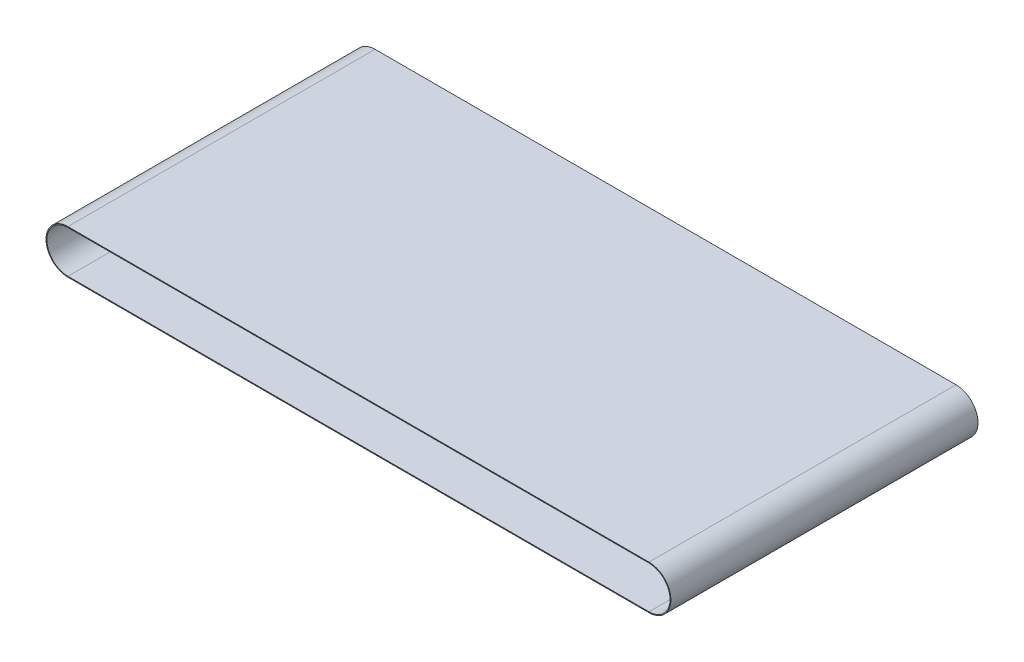
from build123d import *

# Parameters (mm, degrees)
SKETCH_2_W = 370
SKETCH_2_H = 1


with BuildPart() as part:
    # 扫描1: sweep along a path in 草图1
    with BuildLine(Plane(origin=(0, 0, -202.897842698), x_dir=(-1, 0, 0), z_dir=(0, 0, -1))) as sweep_1_path:
        Line((80.56049666, 160.574025873), (780.56049666, 160.574025873))
        ThreePointArc((780.56049666, 160.574025873), (805.56049666, 135.574025873), (780.56049666, 110.574025873))
        Line((780.56049666, 110.574025873), (80.56049666, 110.574025873))
        ThreePointArc((80.56049666, 110.574025873), (55.56049666, 135.574025873), (80.56049666, 160.574025873))
    # 草图2 → 扫描1 (sweep)
    with BuildSketch(Plane(origin=(-80.56049666, 0, 0), x_dir=(0, 0, -1), z_dir=(1, 0, 0))):
        with Locations((17.897842698, 161.5)):
            Rectangle(SKETCH_2_W, SKETCH_2_H)
    sweep(path=sweep_1_path.line)


solid = part.part
